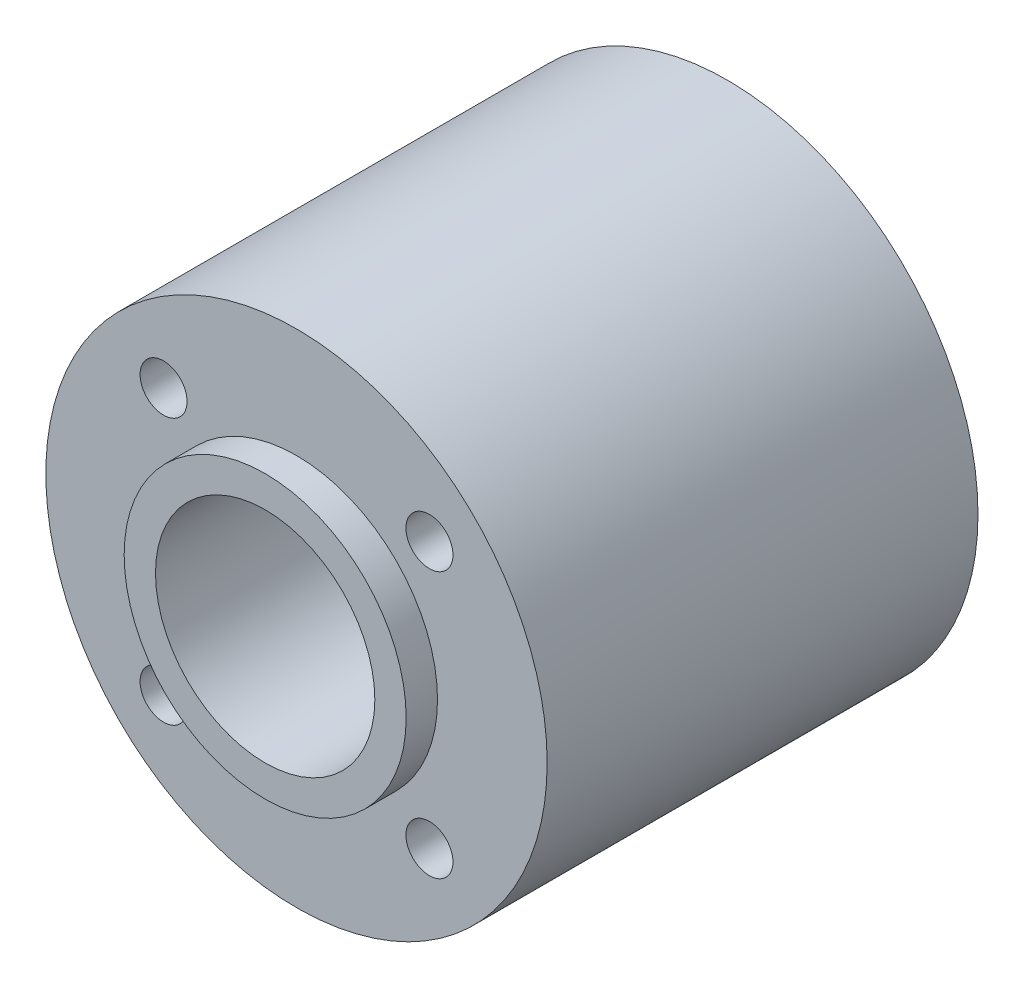
from build123d import *

# Parameters (mm, degrees)
SKETCH1_R           = 16
SKETCH1_R_2         = 7
SKETCH1_R_3         = 1.5
BOSS_EXTRUDE1_DEPTH = 27.5
SKETCH1_3_R         = 9
SKETCH1_3_R_2       = 7
BOSS_EXTRUDE2_DEPTH = 29.5
BOSS_EXTRUDE3_START = -2
SKETCH1_4_R         = 9
SKETCH1_4_R_2       = 7
BOSS_EXTRUDE3_DEPTH = 2


with BuildPart() as part:
    # Sketch1 → Boss-Extrude1 (new body)
    with BuildSketch(Plane.XY):
        Circle(SKETCH1_R)
        Circle(SKETCH1_R_2, mode=Mode.SUBTRACT)
        with Locations((-8.485281374, -8.485281374)):
            Circle(SKETCH1_R_3, mode=Mode.SUBTRACT)
        with Locations((8.485281374, -8.485281374)):
            Circle(SKETCH1_R_3, mode=Mode.SUBTRACT)
        with Locations((-8.485281374, 8.485281374)):
            Circle(SKETCH1_R_3, mode=Mode.SUBTRACT)
        with Locations((8.485281374, 8.485281374)):
            Circle(SKETCH1_R_3, mode=Mode.SUBTRACT)
    extrude(amount=BOSS_EXTRUDE1_DEPTH)

    # Sketch1_3 → Boss-Extrude2 (add)
    with BuildSketch(Plane.XY):
        Circle(SKETCH1_3_R)
        Circle(SKETCH1_3_R_2, mode=Mode.SUBTRACT)
    extrude(amount=BOSS_EXTRUDE2_DEPTH)

    # Sketch1_4 → Boss-Extrude3 (add)
    with BuildSketch(Plane.XY.offset(BOSS_EXTRUDE3_START)):
        Circle(SKETCH1_4_R)
        Circle(SKETCH1_4_R_2, mode=Mode.SUBTRACT)
    extrude(amount=BOSS_EXTRUDE3_DEPTH)


solid = part.part
